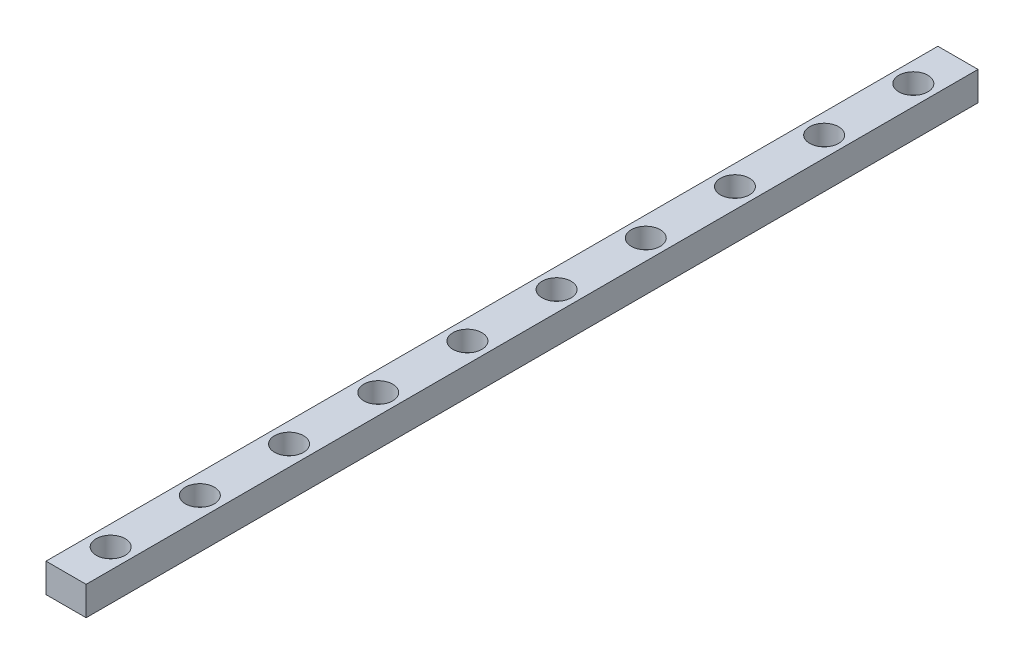
from build123d import *

# Parameters (mm, degrees)
SKETCH1_W                      = 9
SKETCH1_H                      = 6.5
BOSS_EXTRUDE1_DEPTH            = 200
CBORE_FOR_M3_SHCS1_D           = 3.4
CBORE_FOR_M3_SHCS1_CBORE_D     = 6.5
CBORE_FOR_M3_SHCS1_CBORE_DEPTH = 4.5


with BuildPart() as part:
    # Sketch1 → Boss-Extrude1 (new body)
    with BuildSketch(Plane.XY):
        with Locations((4.5, 3.25)):
            Rectangle(SKETCH1_W, SKETCH1_H)
    extrude(amount=BOSS_EXTRUDE1_DEPTH)

    # CBORE for M3 SHCS1 (through all)
    with Locations(Plane(origin=(0, 6.5, 0), x_dir=(1, 0, 0), z_dir=(0, 1, 0))):
        with Locations((4.5, -190), (4.5, -170), (4.5, -150), (4.5, -130), (4.5, -110), (4.5, -90), (4.5, -70), (4.5, -50), (4.5, -30), (4.5, -10)):
            CounterBoreHole(CBORE_FOR_M3_SHCS1_D / 2, CBORE_FOR_M3_SHCS1_CBORE_D / 2, CBORE_FOR_M3_SHCS1_CBORE_DEPTH)


solid = part.part
